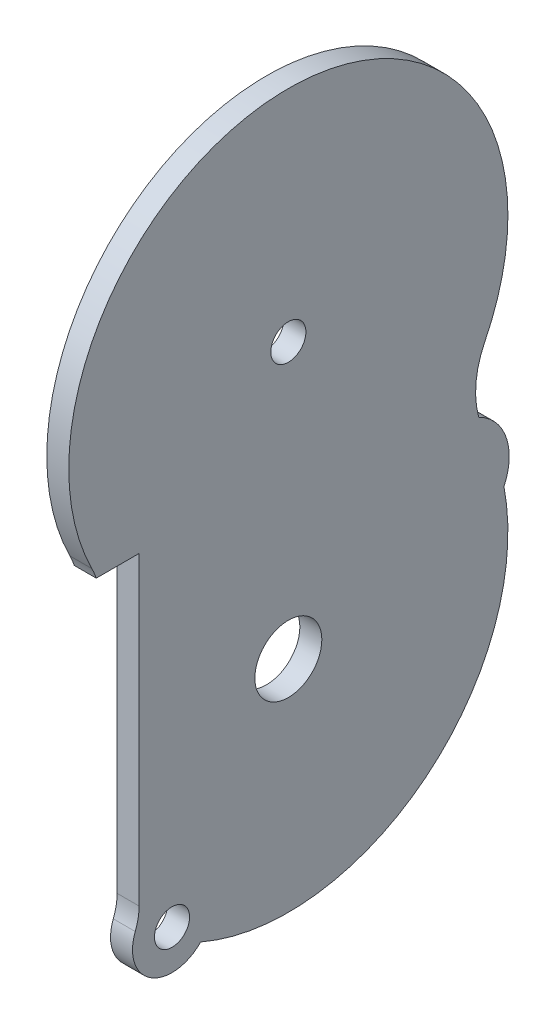
from build123d import *

# Parameters (mm, degrees)
SKETCH1_R           = 1.6
SKETCH1_R_2         = 3.05
BOSS_EXTRUDE1_DEPTH = 2


with BuildPart() as part:
    # Sketch1 → Boss-Extrude1 (new body)
    with BuildSketch(Plane(origin=(-4.933780691, 0, 0), x_dir=(0, 0, -1), z_dir=(1, 0, 0))):
        with BuildLine():
            Line((8.316418793, -3.583005728), (8.316418793, -31.394980118))
            ThreePointArc((8.316418793, -31.394980118), (8.228435382, -32.328839328), (7.967581583, -33.22983289))
            ThreePointArc((7.967581583, -33.22983289), (9.37872929, -37.584960404), (13.923442901, -37.033551565))
            ThreePointArc((13.923442901, -37.033551565), (34.408956218, -34.312472042), (41.551457155, -14.920586884))
            ThreePointArc((41.551457155, -14.920586884), (41.753619834, -11.13958937), (39.247730179, -8.301045906))
            ThreePointArc((39.247730179, -8.301045906), (39.005043324, -5.412218315), (39.807804245, -2.626577156))
            ThreePointArc((39.807804245, -2.626577156), (21.911418793, 26.301994272), (4.015033341, -2.626577156))
            ThreePointArc((4.015033341, -2.626577156), (4.231547099, -3.098268174), (4.417019815, -3.583005728))
            Line((4.417019815, -3.583005728), (8.316418793, -3.583005728))
        make_face()
        with Locations((11.316418793, -34.550926886)):
            Circle(SKETCH1_R, mode=Mode.SUBTRACT)
        with Locations((21.911418793, -18.698005728)):
            Circle(SKETCH1_R_2, mode=Mode.SUBTRACT)
        with Locations((21.911418793, 6.301994272)):
            Circle(SKETCH1_R, mode=Mode.SUBTRACT)
    extrude(amount=BOSS_EXTRUDE1_DEPTH)


solid = part.part
